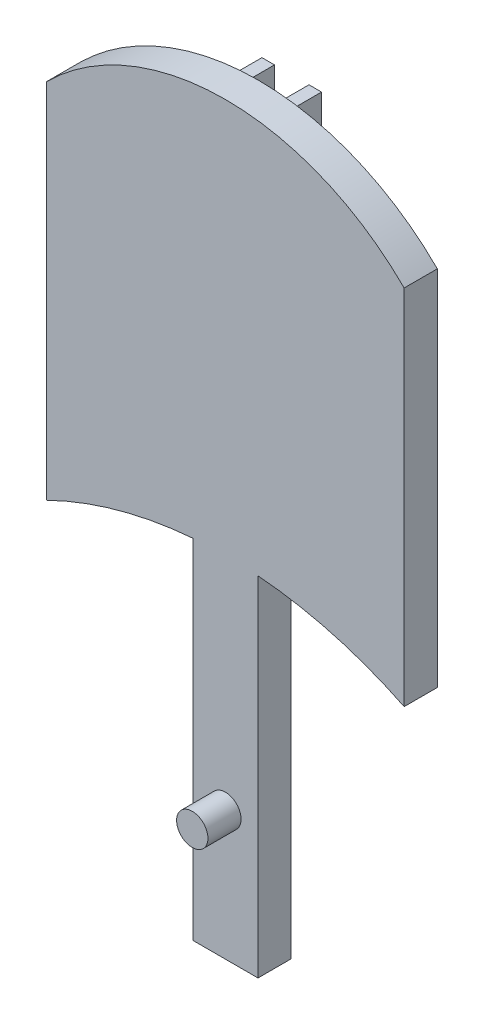
from build123d import *

# Parameters (mm, degrees)
BOSS_EXTRUDE1_DEPTH = 3.175
BOSS_EXTRUDE2_DEPTH = 3.175
SKETCH3_W           = 6.236959702
SKETCH3_H           = 47.194711522
BOSS_EXTRUDE3_DEPTH = 3.175
SKETCH4_R           = 1.5
BOSS_EXTRUDE4_DEPTH = 3.175


with BuildPart() as part:
    # Sketch1 → Boss-Extrude1 (new body)
    with BuildSketch(Plane.XY):
        with BuildLine():
            Line((-17.114253333, -17.357583949), (-17.114253333, 17.357583949))
            ThreePointArc((-17.114253333, 17.357583949), (0, 24.432200125), (17.114253333, 17.357583949))
            Line((17.114253333, 17.357583949), (17.114253333, -17.357583949))
            ThreePointArc((17.114253333, -17.357583949), (0, -13.382802691), (-17.114253333, -17.357583949))
        make_face()
    extrude(amount=BOSS_EXTRUDE1_DEPTH)

    # Sketch2 → Boss-Extrude2 (add)
    with BuildSketch(Plane(origin=(0, 0, 0), x_dir=(-1, 0, 0), z_dir=(0, 0, -1))):
        with BuildLine():
            Line((-1.65128862, -13.417928303), (-1.65128862, 22.268343179))
            Line((-1.65128862, 22.268343179), (-1.65128862, 23.29835294))
            Line((-1.65128862, 23.29835294), (-2.853426735, 23.29835294))
            Line((-2.853426735, 23.29835294), (-2.853426735, -13.48778167))
            ThreePointArc((-2.853426735, -13.48778167), (-2.25262846, -13.448194961), (-1.65128862, -13.417928303))
        make_face()
        with BuildLine():
            Line((1.65128862, 23.29835294), (1.65128862, 22.268343179))
            Line((1.65128862, 22.268343179), (1.65128862, -13.417928303))
            ThreePointArc((1.65128862, -13.417928303), (2.25262846, -13.448194961), (2.853426735, -13.48778167))
            Line((2.853426735, -13.48778167), (2.853426735, 23.29835294))
            Line((2.853426735, 23.29835294), (1.65128862, 23.29835294))
        make_face()
    extrude(amount=BOSS_EXTRUDE2_DEPTH)

    # Sketch3 → Boss-Extrude3 (add)
    with BuildSketch(Plane.XY.offset(3.175)):
        with Locations((0, -23.258467244)):
            Rectangle(SKETCH3_W, SKETCH3_H)
    extrude(amount=-BOSS_EXTRUDE3_DEPTH)

    # Sketch4 → Boss-Extrude4 (add)
    with BuildSketch(Plane.XY.offset(3.175)):
        with Locations((0, -34.503683415)):
            Circle(SKETCH4_R)
    extrude(amount=BOSS_EXTRUDE4_DEPTH)


solid = part.part
